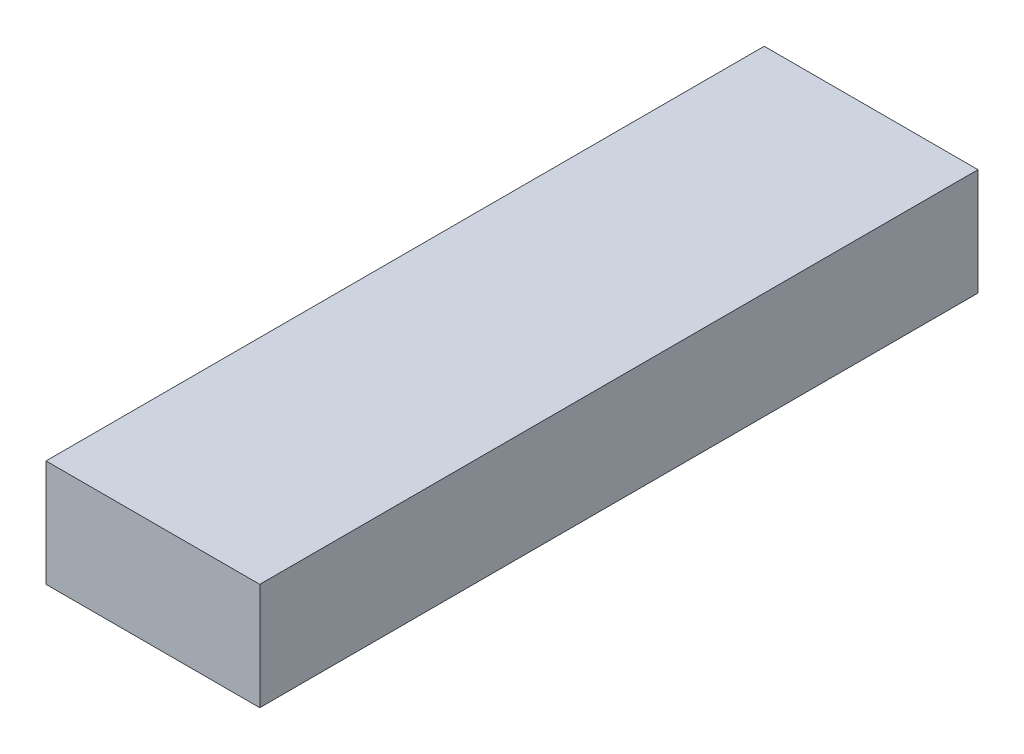
from build123d import *

# Parameters (mm, degrees)
SKETCH1_W           = 6.35
SKETCH1_H           = 21.336
BOSS_EXTRUDE1_DEPTH = 3.175


with BuildPart() as part:
    # Sketch1 → Boss-Extrude1 (new body)
    with BuildSketch(Plane(origin=(0, 0, 0), x_dir=(1, 0, 0), z_dir=(0, 1, 0))):
        with Locations((-0.203346821, -5.800890173)):
            Rectangle(SKETCH1_W, SKETCH1_H)
    extrude(amount=BOSS_EXTRUDE1_DEPTH)


solid = part.part
